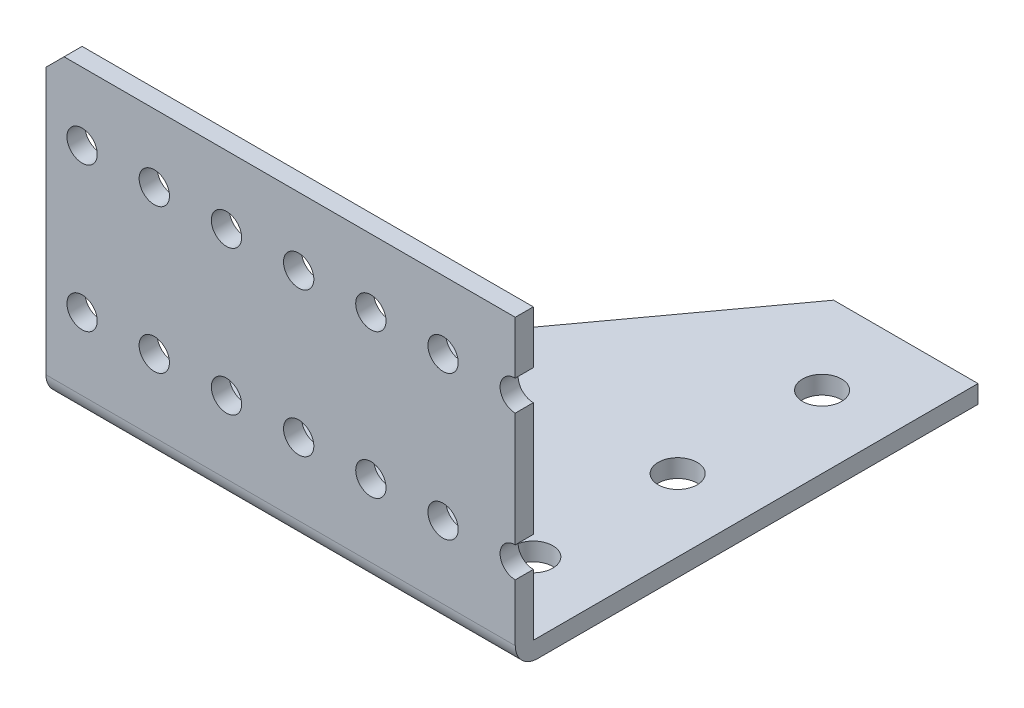
from build123d import *

# Parameters (mm, degrees)
BOSS_EXTRUDE1_START    = -34.925
SKETCH1_W              = 82.55
SKETCH1_H              = 81.407
BOSS_EXTRUDE1_DEPTH    = 3.175
SKETCH3_W              = 82.55
SKETCH3_H              = 3.175
BOSS_EXTRUDE2_DEPTH    = 50.8
F_10_CLEARANCE_HOLE2_D = 5.334
CHAMFER1_SIZE          = 3.175
FILLET2_R              = 3.937
SKETCH9_R              = 3.429
CUT_EXTRUDE2_DEPTH     = 54.975


with BuildPart() as part:
    # Sketch1 → Boss-Extrude1 (new body)
    with BuildSketch(Plane(origin=(0, 0, 0), x_dir=(1, 0, 0), z_dir=(0, 1, 0)).offset(BOSS_EXTRUDE1_START)):
        Rectangle(SKETCH1_W, SKETCH1_H)
    extrude(amount=BOSS_EXTRUDE1_DEPTH)

    # Sketch3 → Boss-Extrude2 (add)
    with BuildSketch(Plane(origin=(0, -31.75, 0), x_dir=(1, 0, 0), z_dir=(0, 1, 0))):
        with Locations((0, -39.116)):
            Rectangle(SKETCH3_W, SKETCH3_H)
    extrude(amount=BOSS_EXTRUDE2_DEPTH)

    # #10 Clearance Hole2 (through all)
    with Locations(Plane(origin=(0, 0, -40.7035), x_dir=(-1, 0, 0), z_dir=(0, 0, -1))):
        with Locations((22.225, 7.112), (9.525, 7.112), (-3.175, 7.112), (-15.875, 7.112), (-28.575, 7.112), (22.225, -18.288), (9.525, -18.288), (-3.175, -18.288), (-15.875, -18.288), (-28.575, -18.288), (34.925, 7.112), (34.925, -18.288), (-41.275, 7.112), (-41.275, -18.288)):
            Hole(F_10_CLEARANCE_HOLE2_D / 2)

    # Chamfer1
    chamfer1_edges = [part.edges().sort_by_distance(p)[0] for p in [
        (-41.275, 19.05, 39.116),
    ]]
    chamfer(chamfer1_edges, length=CHAMFER1_SIZE)

    # Fillet2
    fillet2_edges = [part.edges().sort_by_distance(p)[0] for p in [
        (0, -34.925, 40.7035),
    ]]
    fillet(fillet2_edges, radius=FILLET2_R)

    # Sketch9 → Cut-Extrude2 (cut, through all)
    with BuildSketch(Plane.XZ.offset(34.925)):
        with Locations((28.575, 24.8285)):
            Circle(SKETCH9_R)
        with Locations((28.575, -0.5715)):
            Circle(SKETCH9_R)
        with Locations((28.575, -25.9715)):
            Circle(SKETCH9_R)
        Polygon((-41.275, 37.5285), (15.875, -40.7035), (-41.275, -40.7035), align=None)
    extrude(amount=-CUT_EXTRUDE2_DEPTH, mode=Mode.SUBTRACT)


solid = part.part
